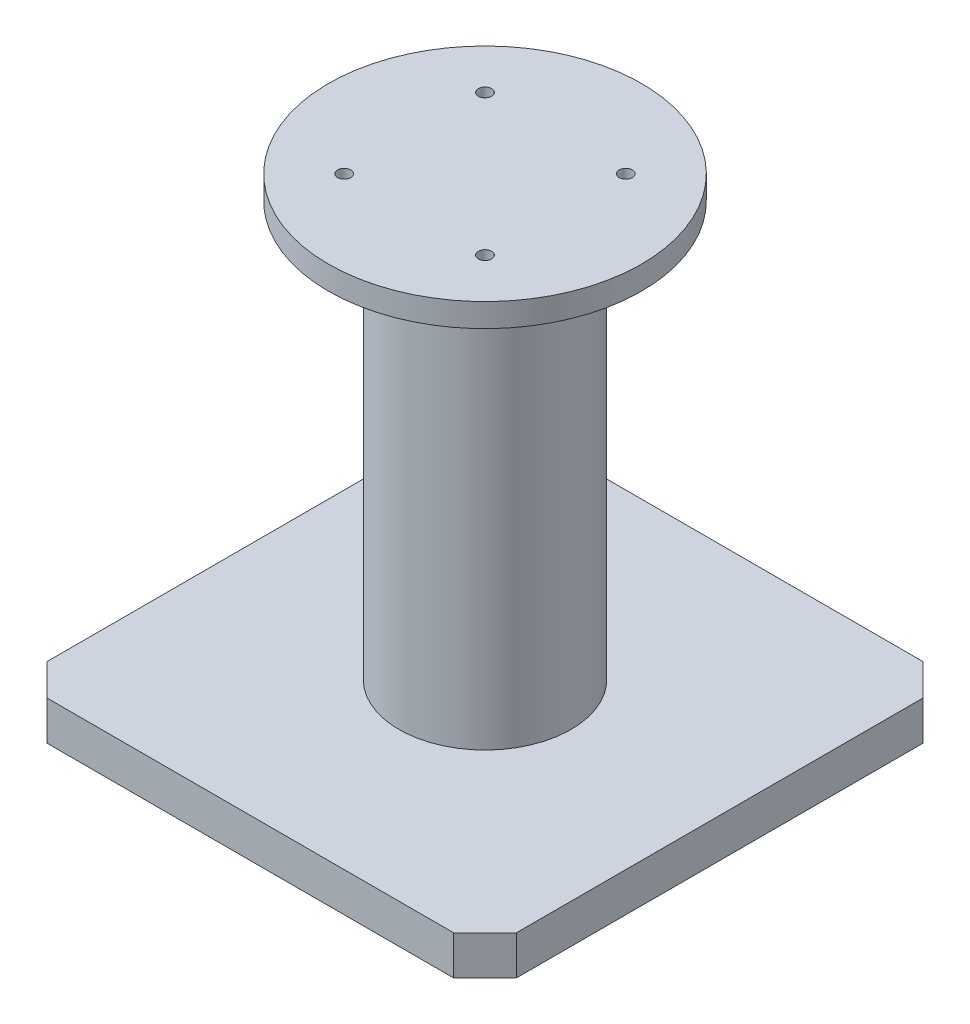
from build123d import *

# Parameters (mm, degrees)
SKETCH1_R           = 100
BOSS_EXTRUDE1_DEPTH = 15
SKETCH2_R           = 55
BOSS_EXTRUDE2_DEPTH = 265
BOSS_EXTRUDE3_DEPTH = 25
SKETCH4_R           = 4.25
CUT_EXTRUDE1_DEPTH  = 25


with BuildPart() as part:
    # Sketch1 → Boss-Extrude1 (new body)
    with BuildSketch(Plane(origin=(0, 0, 0), x_dir=(1, 0, 0), z_dir=(0, 1, 0))):
        Circle(SKETCH1_R)
    extrude(amount=-BOSS_EXTRUDE1_DEPTH)

    # Sketch2 → Boss-Extrude2 (add)
    with BuildSketch(Plane.XZ.offset(15)):
        Circle(SKETCH2_R)
    extrude(amount=BOSS_EXTRUDE2_DEPTH)

    # Sketch3 → Boss-Extrude3 (add)
    with BuildSketch(Plane.XZ.offset(280)):
        Polygon((-150, 130), (-130, 150), (130, 150), (150, 130), (150, -130), (130, -150), (-130, -150), (-150, -130), align=None)
    extrude(amount=BOSS_EXTRUDE3_DEPTH)

    # Sketch4 → Cut-Extrude1 (cut)
    with BuildSketch(Plane(origin=(0, 0, 0), x_dir=(1, 0, 0), z_dir=(0, 1, 0))):
        with Locations((-45, 45)):
            Circle(SKETCH4_R)
        with Locations((45, 45)):
            Circle(SKETCH4_R)
        with Locations((45, -45)):
            Circle(SKETCH4_R)
        with Locations((-45, -45)):
            Circle(SKETCH4_R)
    extrude(amount=-CUT_EXTRUDE1_DEPTH, mode=Mode.SUBTRACT)


solid = part.part
